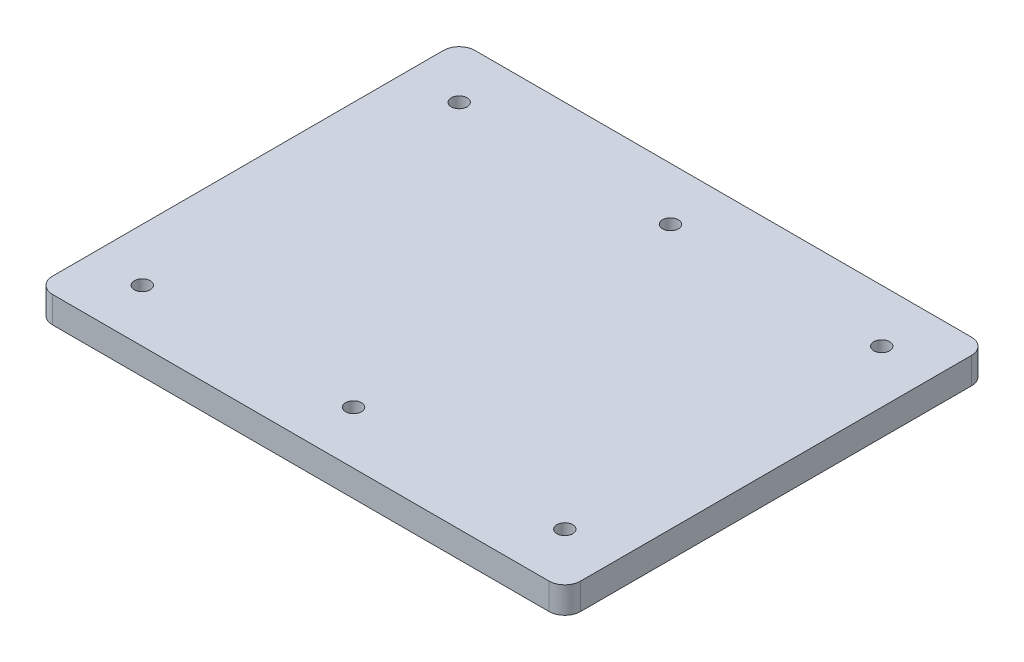
from build123d import *

# Parameters (mm, degrees)
SKETCH_2_W      = 100
SKETCH_2_H      = 80
SKETCH_2_R      = 1.5
EXTRUDE_1_DEPTH = 5
FILLET_1_R      = 3


with BuildPart() as part:
    # 草图2 → 凸台-拉伸1 (new body)
    with BuildSketch(Plane(origin=(0, 0, 0), x_dir=(1, 0, 0), z_dir=(0, 1, 0))):
        with Locations((50, 40)):
            Rectangle(SKETCH_2_W, SKETCH_2_H)
        with Locations((10, 10)):
            Circle(SKETCH_2_R, mode=Mode.SUBTRACT)
        with Locations((50, 10)):
            Circle(SKETCH_2_R, mode=Mode.SUBTRACT)
        with Locations((90, 10)):
            Circle(SKETCH_2_R, mode=Mode.SUBTRACT)
        with Locations((90, 70)):
            Circle(SKETCH_2_R, mode=Mode.SUBTRACT)
        with Locations((50, 70)):
            Circle(SKETCH_2_R, mode=Mode.SUBTRACT)
        with Locations((10, 70)):
            Circle(SKETCH_2_R, mode=Mode.SUBTRACT)
    extrude(amount=EXTRUDE_1_DEPTH)

    # 圆角1
    fillet_1_edges = [part.edges().sort_by_distance(p)[0] for p in [
        (0, 2.5, -80),
        (100, 2.5, -80),
        (100, 2.5, 0),
        (0, 2.5, 0),
    ]]
    fillet(fillet_1_edges, radius=FILLET_1_R)


solid = part.part
